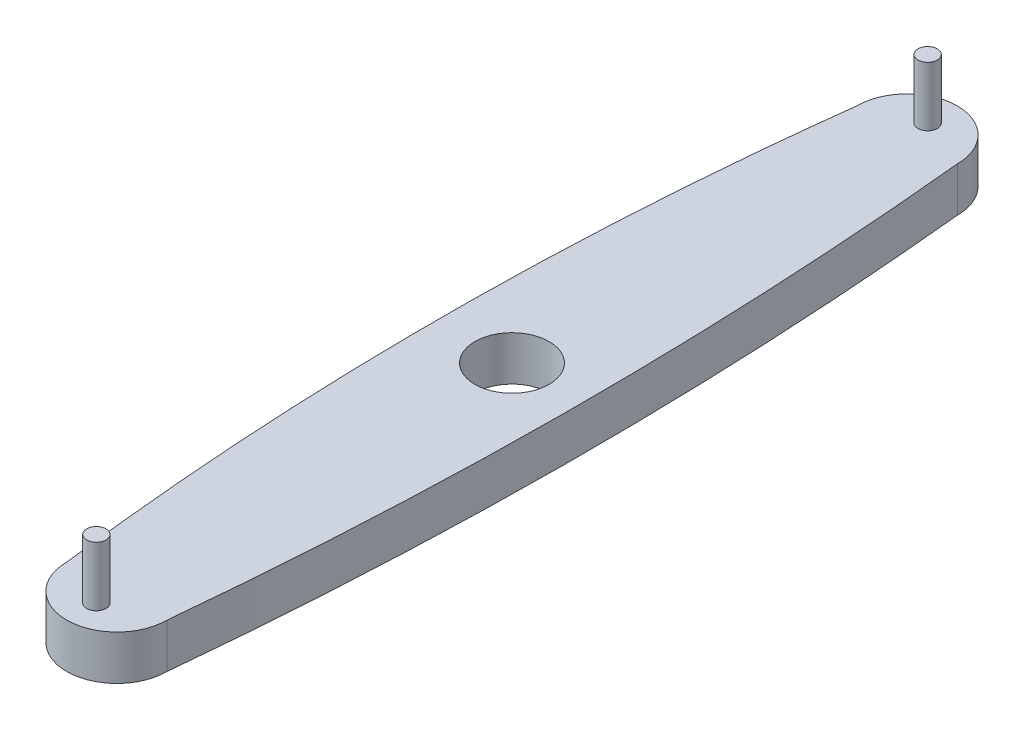
from build123d import *

# Parameters (mm, degrees)
BOSS_EXTRUDE1_DEPTH = 30
SKETCH2_R           = 25
CUT_EXTRUDE1_DEPTH  = 30
SKETCH3_R           = 6.505
BOSS_EXTRUDE2_DEPTH = 40
CUT_EXTRUDE2_DEPTH  = 40


with BuildPart() as part:
    # Sketch1 → Boss-Extrude1 (new body)
    with BuildSketch(Plane(origin=(0, 0, 0), x_dir=(1, 0, 0), z_dir=(0, 1, 0))):
        with BuildLine():
            Line((-77.61802258, 0), (-33.820586084, 266.179413916))
            ThreePointArc((-33.820586084, 266.179413916), (0, 300), (33.820586084, 266.179413916))
            Line((33.820586084, 266.179413916), (72.176610565, 0))
            Line((72.176610565, 0), (33.820586084, -266.179413916))
            ThreePointArc((33.820586084, -266.179413916), (0, -300), (-33.820586084, -266.179413916))
            Line((-33.820586084, -266.179413916), (-77.61802258, 0))
        make_face()
    extrude(amount=BOSS_EXTRUDE1_DEPTH)

    # Sketch2 → Cut-Extrude1 (cut)
    with BuildSketch(Plane(origin=(0, 30, 0), x_dir=(1, 0, 0), z_dir=(0, 1, 0))):
        Circle(SKETCH2_R)
    extrude(amount=-CUT_EXTRUDE1_DEPTH, mode=Mode.SUBTRACT)

    # Sketch3 → Boss-Extrude2 (add)
    with BuildSketch(Plane(origin=(0, 30, 0), x_dir=(1, 0, 0), z_dir=(0, 1, 0))):
        with Locations((0, -280)):
            Circle(SKETCH3_R)
    boss_extrude2 = extrude(amount=BOSS_EXTRUDE2_DEPTH)

    # Mirror1: Boss-Extrude2 across plane
    add(boss_extrude2.mirror(Plane.XY))

    # Sketch4 → Cut-Extrude2 (cut)
    with BuildSketch(Plane(origin=(0, 30, 0), x_dir=(1, 0, 0), z_dir=(0, 1, 0))):
        with BuildLine():
            Line((-77.61802258, 0), (-33.820586084, -266.179413916))
            add(Edge.make_bspline(
                [(-33.820586084, 266.179413916), (-66.842002298, 0), (-33.820586084, -266.179413916)],
                knots=[0, 0, 0, 1, 1, 1], degree=2))
            add(Edge.make_bspline(
                [(-33.820586084, 266.179413916), (-77.61802258, 0)],
                knots=[0, 0, 1, 1], degree=1))
        make_face()
        with BuildLine():
            Line((72.176610565, 0), (33.820586084, 266.179413916))
            add(Edge.make_bspline(
                [(33.820586084, 266.179413916), (60.12786219, -0.030187119), (33.820586084, -266.179413916)],
                knots=[0, 0, 0, 1, 1, 1], degree=2))
            Line((33.820586084, -266.179413916), (72.176610565, 0))
        make_face()
    extrude(amount=-CUT_EXTRUDE2_DEPTH, mode=Mode.SUBTRACT)


solid = part.part
